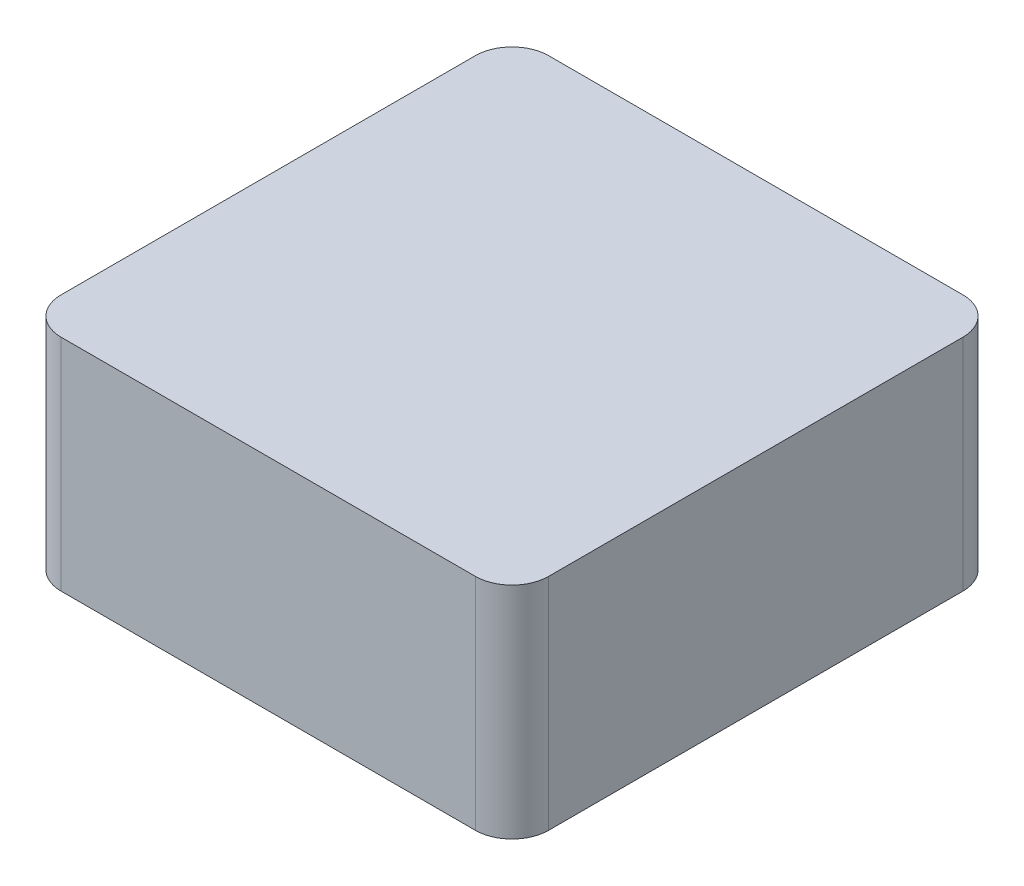
from build123d import *

# Parameters (mm, degrees)
SKETCH1_W           = 6.65
SKETCH1_H           = 6.65
BOSS_EXTRUDE1_DEPTH = 3
FILLET1_R           = 0.5


with BuildPart() as part:
    # Sketch1 → Boss-Extrude1 (new body)
    with BuildSketch(Plane(origin=(0, 0, 0), x_dir=(1, 0, 0), z_dir=(0, 1, 0))):
        Rectangle(SKETCH1_W, SKETCH1_H)
    extrude(amount=BOSS_EXTRUDE1_DEPTH)

    # Fillet1
    fillet1_edges = [part.edges().sort_by_distance(p)[0] for p in [
        (3.325, 1.5, 3.325),
        (-3.325, 1.5, 3.325),
        (-3.325, 1.5, -3.325),
        (3.325, 1.5, -3.325),
    ]]
    fillet(fillet1_edges, radius=FILLET1_R)


solid = part.part
